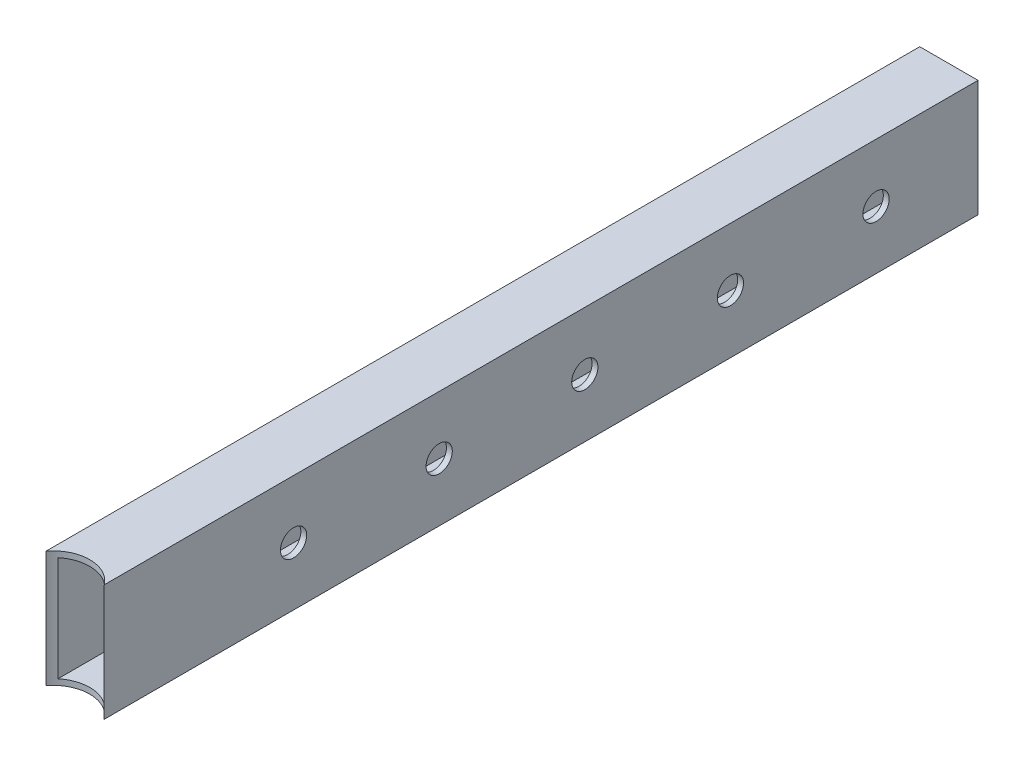
from build123d import *

# Parameters (mm, degrees)
SKETCH_1_W          = 20
SKETCH_1_H          = 40
SKETCH_1_W_2        = 16
SKETCH_1_H_2        = 36
EXTRUDE_1_DEPTH     = 300
SKETCH_2_R          = 12.5
CUT_EXTRUDE_1_DEPTH = 40
SKETCH_3_R          = 4.5
CUT_EXTRUDE_2_DEPTH = 2


with BuildPart() as part:
    # Эскиз1 → Бобышка-Вытянуть1 (new body)
    with BuildSketch(Plane.XY):
        Rectangle(SKETCH_1_W, SKETCH_1_H)
        Rectangle(SKETCH_1_W_2, SKETCH_1_H_2, mode=Mode.SUBTRACT)
    extrude(amount=EXTRUDE_1_DEPTH)

    # Эскиз2 → Вырез-Вытянуть1 (cut)
    with BuildSketch(Plane(origin=(0, 20, 0), x_dir=(1, 0, 0), z_dir=(0, 1, 0))):
        with Locations((0, -307.5)):
            Circle(SKETCH_2_R)
    extrude(amount=-CUT_EXTRUDE_1_DEPTH, mode=Mode.SUBTRACT)

    # Эскиз3 → Вырез-Вытянуть2 (cut)
    with BuildSketch(Plane(origin=(10, 0, 0), x_dir=(0, 0, -1), z_dir=(1, 0, 0))):
        with Locations(Location((-35, 0, 0), (0, 0, 90))):  # turned: the seam where the file's is
            Circle(SKETCH_3_R)
        with Locations(Location((-85, 0, 0), (0, 0, 90))):  # turned: the seam where the file's is
            Circle(SKETCH_3_R)
        with Locations(Location((-135, 0, 0), (0, 0, 90))):  # turned: the seam where the file's is
            Circle(SKETCH_3_R)
        with Locations(Location((-185, 0, 0), (0, 0, 90))):  # turned: the seam where the file's is
            Circle(SKETCH_3_R)
        with Locations(Location((-235, 0, 0), (0, 0, 90))):  # turned: the seam where the file's is
            Circle(SKETCH_3_R)
    extrude(amount=-CUT_EXTRUDE_2_DEPTH, mode=Mode.SUBTRACT)


solid = part.part
